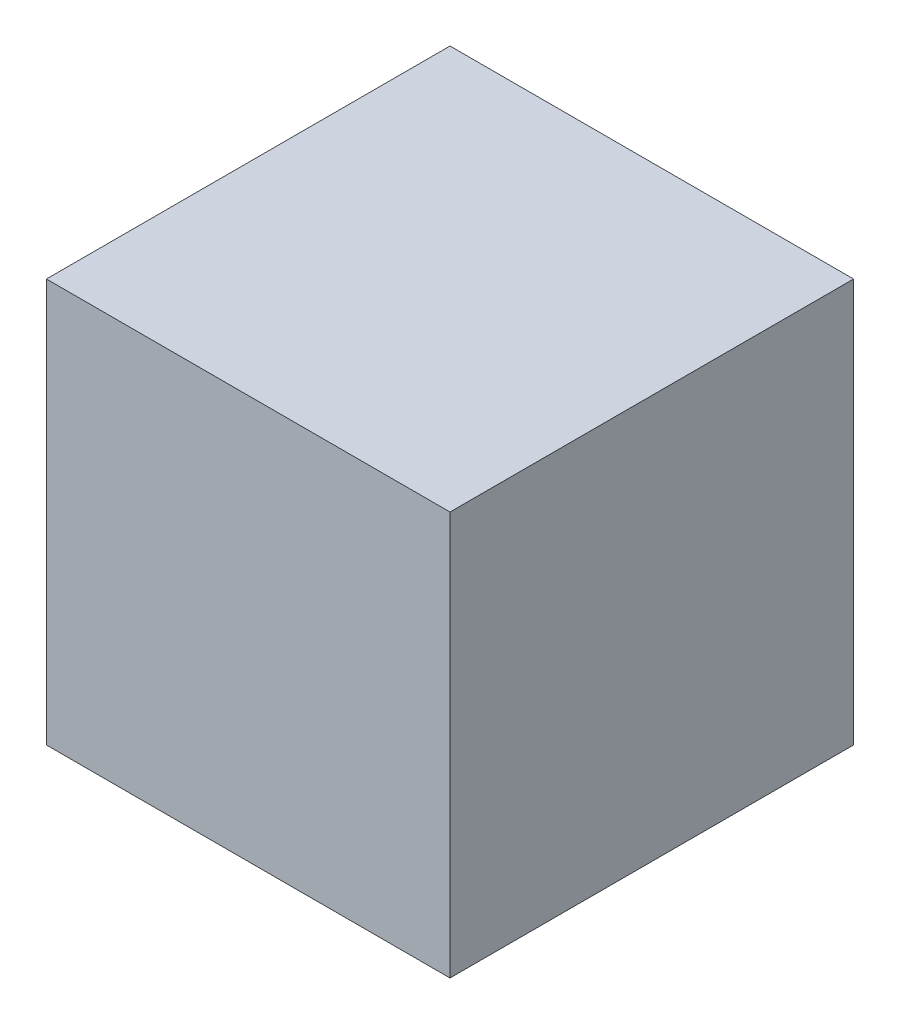
from build123d import *

# Parameters (mm, degrees)
SKIZZE1_W                       = 1
SKIZZE1_H                       = 1
AUFSATZ_LINEAR_AUSTRAGEN1_DEPTH = 0.5


with BuildPart() as part:
    # Skizze1 → Aufsatz-Linear austragen1 (new body, symmetric)
    with BuildSketch(Plane(origin=(0, 0, 0), x_dir=(1, 0, 0), z_dir=(0, 1, 0))):
        Rectangle(SKIZZE1_W, SKIZZE1_H)
    extrude(amount=AUFSATZ_LINEAR_AUSTRAGEN1_DEPTH, both=True)


solid = part.part
